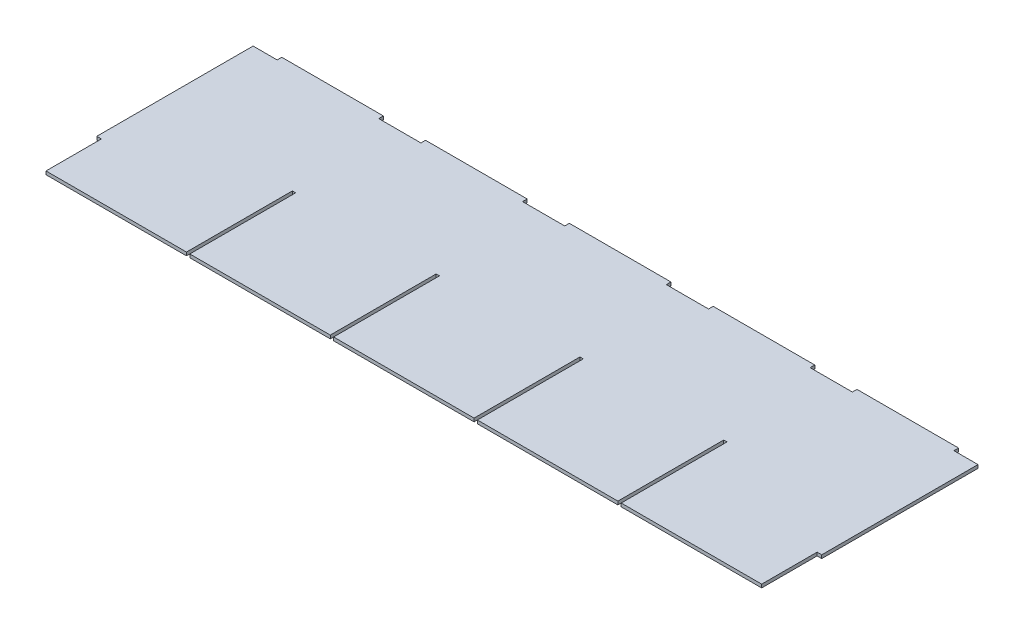
from build123d import *

# Parameters (mm, degrees)
SKETCH1_W           = 498.348
SKETCH1_H           = 145.542
BOSS_EXTRUDE1_DEPTH = 1.143
SKETCH2_W           = 69.85
SKETCH2_H           = 2.286
BOSS_EXTRUDE2_DEPTH = 3.175
LPATTERN1_COUNT     = 5
LPATTERN1_PITCH     = 98.8568
SKETCH3_W           = 3.175
SKETCH3_H           = 38.1
CUT_EXTRUDE1_DEPTH  = 3.286
SKETCH5_W           = 2.286
SKETCH5_H           = 72.771
CUT_EXTRUDE2_DEPTH  = 3.286
LPATTERN2_COUNT     = 4
LPATTERN2_PITCH     = 98.8568


with BuildPart() as part:
    # Sketch1 → Boss-Extrude1 (new body, symmetric)
    with BuildSketch(Plane(origin=(0, 0, 0), x_dir=(1, 0, 0), z_dir=(0, 1, 0))):
        Rectangle(SKETCH1_W, SKETCH1_H)
    extrude(amount=BOSS_EXTRUDE1_DEPTH, both=True)

    # Sketch2 → Boss-Extrude2 (add)
    with BuildSketch(Plane(origin=(0, 0, -72.771), x_dir=(-1, 0, 0), z_dir=(0, 0, -1))):
        with Locations((-197.7136, 0)):
            Rectangle(SKETCH2_W, SKETCH2_H)
    boss_extrude2 = extrude(amount=BOSS_EXTRUDE2_DEPTH)

    # LPattern1: Boss-Extrude2 ×5
    with Locations(*[(-i * LPATTERN1_PITCH, 0, 0) for i in range(1, LPATTERN1_COUNT)]):
        add(boss_extrude2)

    # Sketch3 → Cut-Extrude1 (cut, through all)
    with BuildSketch(Plane.XZ.offset(1.143)):
        with Locations((-247.5865, 53.721)):
            Rectangle(SKETCH3_W, SKETCH3_H)
    cut_extrude1 = extrude(amount=-CUT_EXTRUDE1_DEPTH, mode=Mode.SUBTRACT)

    # Mirror2: Cut-Extrude1 across plane
    add(cut_extrude1.mirror(Plane(origin=(0, 0, 0), x_dir=(0, 0, 1), z_dir=(1, 0, 0))), mode=Mode.SUBTRACT)

    # Sketch5 → Cut-Extrude2 (cut, through all)
    with BuildSketch(Plane.XZ.offset(1.143)):
        with Locations((-148.2852, 36.3855)):
            Rectangle(SKETCH5_W, SKETCH5_H)
    cut_extrude2 = extrude(amount=-CUT_EXTRUDE2_DEPTH, mode=Mode.SUBTRACT)

    # LPattern2: Cut-Extrude2 ×4
    with Locations(*[(i * LPATTERN2_PITCH, 0, 0) for i in range(1, LPATTERN2_COUNT)]):
        add(cut_extrude2, mode=Mode.SUBTRACT)


solid = part.part
